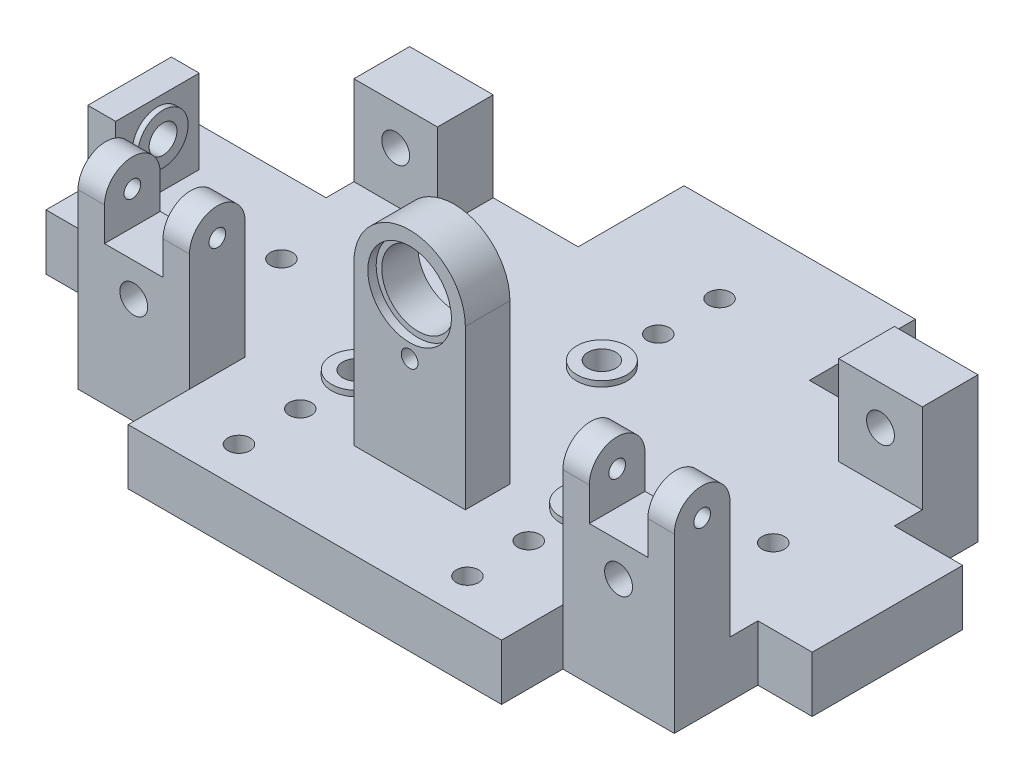
from build123d import *

# Parameters (mm, degrees)
EXTRUDE_1_DEPTH          = 20
SKETCH_3_W               = 10
SKETCH_3_H               = 30
EXTRUDE_2_DEPTH          = 30
SKETCH_5_W               = 40
SKETCH_5_H               = 20
EXTRUDE_3_DEPTH          = 42
SKETCH_2_R               = 5
CUT_EXTRUDE_1_DEPTH      = 13
CUT_EXTRUDE_2_REACH      = 17
SKETCH_4_R               = 5
CUT_EXTRUDE_3_REACH      = 44
SKETCH_6_R               = 5
SKETCH_7_R               = 9
SKETCH_7_R_2             = 5
EXTRUDE_4_DEPTH          = 2
SKETCH_8_R               = 9
SKETCH_8_R_2             = 5
EXTRUDE_5_DEPTH          = 2
SKETCH_9_R               = 9
SKETCH_9_R_2             = 5
EXTRUDE_6_DEPTH          = 2
SKETCH_10_R              = 4
CUT_EXTRUDE_4_DEPTH      = 21
SKETCH_11_W              = 40
SKETCH_11_H              = 16
EXTRUDE_7_DEPTH          = 57
SKETCH_12_W              = 20
SKETCH_12_H              = 16
REVOLVE_1_ANGLE          = 180
SKETCH_13_R              = 15
CUT_EXTRUDE_5_DEPTH      = 35
CUT_EXTRUDE_5_DEPTH_BACK = 3
CUT_EXTRUDE_6_REACH      = 139
SKETCH_14_R              = 13
SKETCH_15_R              = 3
CUT_EXTRUDE_7_DEPTH      = 12
SKETCH_16_W              = 9.5
SKETCH_16_H              = 10
SKETCH_17_W              = 21
SKETCH_17_H              = 20
CUT_EXTRUDE_8_DEPTH      = 12
SKETCH_18_R              = 3
CUT_EXTRUDE_9_DEPTH      = 40
SKETCH_19_R              = 3
CUT_EXTRUDE_10_DEPTH     = 40
SKETCH_20_W              = 30
SKETCH_20_H              = 20
EXTRUDE_8_DEPTH          = 32
CUT_EXTRUDE_11_REACH     = 60
SKETCH_21_R              = 5


with BuildPart() as part:
    # 草图1 → 凸台-拉伸1 (new body)
    with BuildSketch(Plane(origin=(0, 0, 0), x_dir=(1, 0, 0), z_dir=(0, 1, 0))):
        Polygon((-102, 136), (-41.5, 136), (-41.5, 174), (41.5, 174), (41.5, 136), (102, 136), (102, 106), (126.5, 106), (126.5, 52), (107, 52), (107, 22), (67, 22), (67, 0), (-67, 0), (-67, 22), (-107, 22), (-107, 52), (-148.5, 52), (-148.5, 106), (-102, 106), align=None)
    extrude(amount=EXTRUDE_1_DEPTH)

    # 草图3 → 凸台-拉伸2 (add)
    with BuildSketch(Plane(origin=(0, 20, 0), x_dir=(1, 0, 0), z_dir=(0, 1, 0))):
        with Locations((-138.5, 77)):
            Rectangle(SKETCH_3_W, SKETCH_3_H)
    extrude(amount=EXTRUDE_2_DEPTH)

    # 草图5 → 凸台-拉伸3 (add)
    with BuildSketch(Plane(origin=(0, 20, 0), x_dir=(1, 0, 0), z_dir=(0, 1, 0))):
        with Locations((-87, 32)):
            Rectangle(SKETCH_5_W, SKETCH_5_H)
        with Locations((87, 32)):
            Rectangle(SKETCH_5_W, SKETCH_5_H)
    extrude(amount=EXTRUDE_3_DEPTH)

    # 草图2 → 切除-拉伸1 (cut)
    with BuildSketch(Plane(origin=(0, 20, 0), x_dir=(1, 0, 0), z_dir=(0, 1, 0))):
        with Locations((0, 103)):
            Circle(SKETCH_2_R)
        with Locations((-41, 56)):
            Circle(SKETCH_2_R)
        with Locations((41, 56)):
            Circle(SKETCH_2_R)
    extrude(amount=-CUT_EXTRUDE_1_DEPTH, mode=Mode.SUBTRACT)

    # 草图4 → 切除-拉伸2 (cut, up to next)
    with BuildSketch(Plane(origin=(-133.5, 0, 0), x_dir=(0, 0, -1), z_dir=(1, 0, 0)), mode=Mode.PRIVATE) as cut_extrude_2_sk1:
        with Locations((77, 38)):
            Circle(SKETCH_4_R)
    cut_extrude_2_tool1 = extrude(cut_extrude_2_sk1.sketch, amount=-CUT_EXTRUDE_2_REACH, mode=Mode.PRIVATE) & part.part
    add(cut_extrude_2_tool1.solids().sort_by_distance((-133.5, 38, -77))[0], mode=Mode.SUBTRACT)

    # 草图6 → 切除-拉伸3 (cut, up to next)
    with BuildSketch(Plane(origin=(0, 0, -42), x_dir=(-1, 0, 0), z_dir=(0, 0, -1)), mode=Mode.PRIVATE) as cut_extrude_3_sk1:
        with Locations((87, 38)):
            Circle(SKETCH_6_R)
    cut_extrude_3_tool1 = extrude(cut_extrude_3_sk1.sketch, amount=-CUT_EXTRUDE_3_REACH, mode=Mode.PRIVATE) & part.part
    add(cut_extrude_3_tool1.solids().sort_by_distance((-87, 38, -42))[0], mode=Mode.SUBTRACT)
    # 草图6 → 切除-拉伸3 (cut, up to next)
    with BuildSketch(Plane(origin=(0, 0, -42), x_dir=(-1, 0, 0), z_dir=(0, 0, -1)), mode=Mode.PRIVATE) as cut_extrude_3_sk2:
        with Locations((-87, 38)):
            Circle(SKETCH_6_R)
    cut_extrude_3_tool2 = extrude(cut_extrude_3_sk2.sketch, amount=-CUT_EXTRUDE_3_REACH, mode=Mode.PRIVATE) & part.part
    add(cut_extrude_3_tool2.solids().sort_by_distance((87, 38, -42))[0], mode=Mode.SUBTRACT)

    # 草图7 → 凸台-拉伸4 (add)
    with BuildSketch(Plane(origin=(-133.5, 0, 0), x_dir=(0, 0, -1), z_dir=(1, 0, 0))):
        with Locations((77, 38)):
            Circle(SKETCH_7_R)
        with Locations((77, 38)):
            Circle(SKETCH_7_R_2, mode=Mode.SUBTRACT)
    extrude(amount=EXTRUDE_4_DEPTH)

    # 草图8 → 凸台-拉伸5 (add)
    with BuildSketch(Plane(origin=(0, 0, -42), x_dir=(-1, 0, 0), z_dir=(0, 0, -1))):
        with Locations((-87, 38)):
            Circle(SKETCH_8_R)
        with Locations((-87, 38)):
            Circle(SKETCH_8_R_2, mode=Mode.SUBTRACT)
        with Locations((87, 38)):
            Circle(SKETCH_8_R)
        with Locations((87, 38)):
            Circle(SKETCH_8_R_2, mode=Mode.SUBTRACT)
    extrude(amount=EXTRUDE_5_DEPTH)

    # 草图9 → 凸台-拉伸6 (add)
    with BuildSketch(Plane(origin=(0, 20, 0), x_dir=(1, 0, 0), z_dir=(0, 1, 0))):
        with Locations((-41, 56)):
            Circle(SKETCH_9_R)
        with Locations((-41, 56)):
            Circle(SKETCH_9_R_2, mode=Mode.SUBTRACT)
        with Locations((0, 103)):
            Circle(SKETCH_9_R)
        with Locations((0, 103)):
            Circle(SKETCH_9_R_2, mode=Mode.SUBTRACT)
        with Locations((41, 56)):
            Circle(SKETCH_9_R)
        with Locations((41, 56)):
            Circle(SKETCH_9_R_2, mode=Mode.SUBTRACT)
    extrude(amount=EXTRUDE_6_DEPTH)

    # 草图10 → 切除-拉伸4 (cut, through all)
    with BuildSketch(Plane(origin=(0, 20, 0), x_dir=(1, 0, 0), z_dir=(0, 1, 0))):
        with Locations((-41, 35.75)):
            Circle(SKETCH_10_R)
        with Locations((41, 35.75)):
            Circle(SKETCH_10_R)
        with Locations((-41, 13.75)):
            Circle(SKETCH_10_R)
        with Locations((41, 13.75)):
            Circle(SKETCH_10_R)
        with Locations((-91, 79)):
            Circle(SKETCH_10_R)
        with Locations((0, 123.25)):
            Circle(SKETCH_10_R)
        with Locations((0, 145.25)):
            Circle(SKETCH_10_R)
        with Locations((85.5, 79)):
            Circle(SKETCH_10_R)
    extrude(amount=-CUT_EXTRUDE_4_DEPTH, mode=Mode.SUBTRACT)

    # 草图11 → 凸台-拉伸7 (add)
    with BuildSketch(Plane(origin=(0, 20, 0), x_dir=(1, 0, 0), z_dir=(0, 1, 0))):
        with Locations((0, 42)):
            Rectangle(SKETCH_11_W, SKETCH_11_H)
    extrude(amount=EXTRUDE_7_DEPTH)

    # 草图12 → 旋转1 (revolve)
    with BuildSketch(Plane(origin=(0, 77, 0), x_dir=(1, 0, 0), z_dir=(0, 1, 0))):
        with Locations((-10, 42)):
            Rectangle(SKETCH_12_W, SKETCH_12_H)
    revolve(axis=Axis((0, 77, -50), (0, 0, -1)), revolution_arc=REVOLVE_1_ANGLE)

    # 草图13 → 切除-拉伸5 (cut, two sides)
    with BuildSketch(Plane.XY.offset(-34)) as cut_extrude_5_sk:
        with Locations((0, 77)):
            Circle(SKETCH_13_R)
    extrude(amount=CUT_EXTRUDE_5_DEPTH, mode=Mode.SUBTRACT)
    extrude(cut_extrude_5_sk.sketch, amount=-CUT_EXTRUDE_5_DEPTH_BACK, mode=Mode.SUBTRACT)

    # 草图14 → 切除-拉伸6 (cut, up to next)
    with BuildSketch(Plane.XY.offset(-37), mode=Mode.PRIVATE) as cut_extrude_6_sk1:
        with Locations((0, 77)):
            Circle(SKETCH_14_R)
    cut_extrude_6_tool1 = extrude(cut_extrude_6_sk1.sketch, amount=-CUT_EXTRUDE_6_REACH, mode=Mode.PRIVATE) & part.part
    add(cut_extrude_6_tool1.solids().sort_by_distance((0, 77, -37))[0], mode=Mode.SUBTRACT)

    # 草图15 → 切除-拉伸7 (cut)
    with BuildSketch(Plane.XY.offset(-34)):
        with Locations((0, 57)):
            Circle(SKETCH_15_R)
    extrude(amount=-CUT_EXTRUDE_7_DEPTH, mode=Mode.SUBTRACT)

    # 草图16 → 旋转2 (revolve)
    with BuildSketch(Plane(origin=(0, 62, 0), x_dir=(1, 0, 0), z_dir=(0, 1, 0))):
        with Locations((-102.25, 37)):
            Rectangle(SKETCH_16_W, SKETCH_16_H)
        with Locations((-71.75, 37)):
            Rectangle(SKETCH_16_W, SKETCH_16_H)
        with Locations((102.25, 37)):
            Rectangle(SKETCH_16_W, SKETCH_16_H)
        with Locations((71.75, 37)):
            Rectangle(SKETCH_16_W, SKETCH_16_H)
    revolve(axis=Axis((107, 62, -32), (-1, 0, 0)))

    # 草图17 → 切除-拉伸8 (cut)
    with BuildSketch(Plane(origin=(0, 62, 0), x_dir=(1, 0, 0), z_dir=(0, 1, 0))):
        with Locations((-87, 32)):
            Rectangle(SKETCH_17_W, SKETCH_17_H)
        with Locations((87, 32)):
            Rectangle(SKETCH_17_W, SKETCH_17_H)
    extrude(amount=-CUT_EXTRUDE_8_DEPTH, mode=Mode.SUBTRACT)

    # 草图18 → 切除-拉伸9 (cut)
    with BuildSketch(Plane.ZY.offset(107)):
        with Locations((-32, 62)):
            Circle(SKETCH_18_R)
    extrude(amount=-CUT_EXTRUDE_9_DEPTH, mode=Mode.SUBTRACT)

    # 草图19 → 切除-拉伸10 (cut)
    with BuildSketch(Plane(origin=(107, 0, 0), x_dir=(0, 0, -1), z_dir=(1, 0, 0))):
        with Locations((32, 62)):
            Circle(SKETCH_19_R)
    extrude(amount=-CUT_EXTRUDE_10_DEPTH, mode=Mode.SUBTRACT)

    # 草图20 → 凸台-拉伸8 (add)
    with BuildSketch(Plane(origin=(0, 20, 0), x_dir=(1, 0, 0), z_dir=(0, 1, 0))):
        with Locations((-87, 126)):
            Rectangle(SKETCH_20_W, SKETCH_20_H)
        with Locations((87, 126)):
            Rectangle(SKETCH_20_W, SKETCH_20_H)
    extrude(amount=EXTRUDE_8_DEPTH)

    # 草图21 → 切除-拉伸11 (cut, up to next)
    with BuildSketch(Plane.XY.offset(-116), mode=Mode.PRIVATE) as cut_extrude_11_sk1:
        with Locations((87, 38)):
            Circle(SKETCH_21_R)
    cut_extrude_11_tool1 = extrude(cut_extrude_11_sk1.sketch, amount=-CUT_EXTRUDE_11_REACH, mode=Mode.PRIVATE) & part.part
    add(cut_extrude_11_tool1.solids().sort_by_distance((87, 38, -116))[0], mode=Mode.SUBTRACT)
    # 草图21 → 切除-拉伸11 (cut, up to next)
    with BuildSketch(Plane.XY.offset(-116), mode=Mode.PRIVATE) as cut_extrude_11_sk2:
        with Locations((-87, 38)):
            Circle(SKETCH_21_R)
    cut_extrude_11_tool2 = extrude(cut_extrude_11_sk2.sketch, amount=-CUT_EXTRUDE_11_REACH, mode=Mode.PRIVATE) & part.part
    add(cut_extrude_11_tool2.solids().sort_by_distance((-87, 38, -116))[0], mode=Mode.SUBTRACT)


solid = part.part
